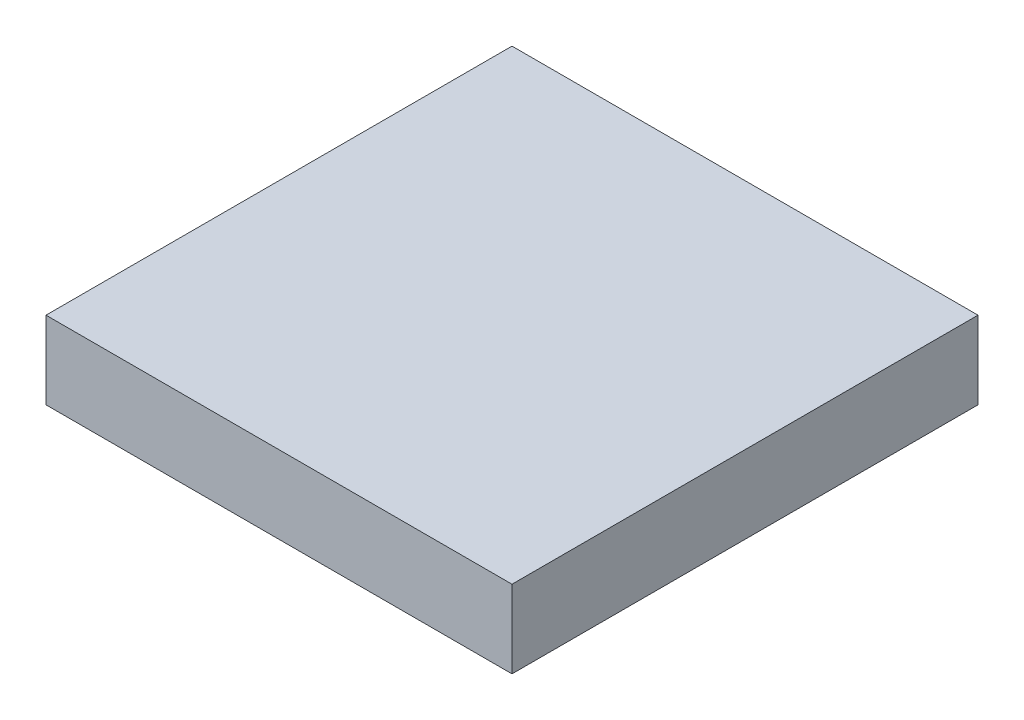
from build123d import *

# Parameters (mm, degrees)
SKETCH1_W           = 12
SKETCH1_H           = 12
BOSS_EXTRUDE1_DEPTH = 2


with BuildPart() as part:
    # Sketch1 → Boss-Extrude1 (new body)
    with BuildSketch(Plane(origin=(0, 0, 0), x_dir=(1, 0, 0), z_dir=(0, 1, 0))):
        with Locations((6, 6)):
            Rectangle(SKETCH1_W, SKETCH1_H)
    extrude(amount=BOSS_EXTRUDE1_DEPTH)


solid = part.part
